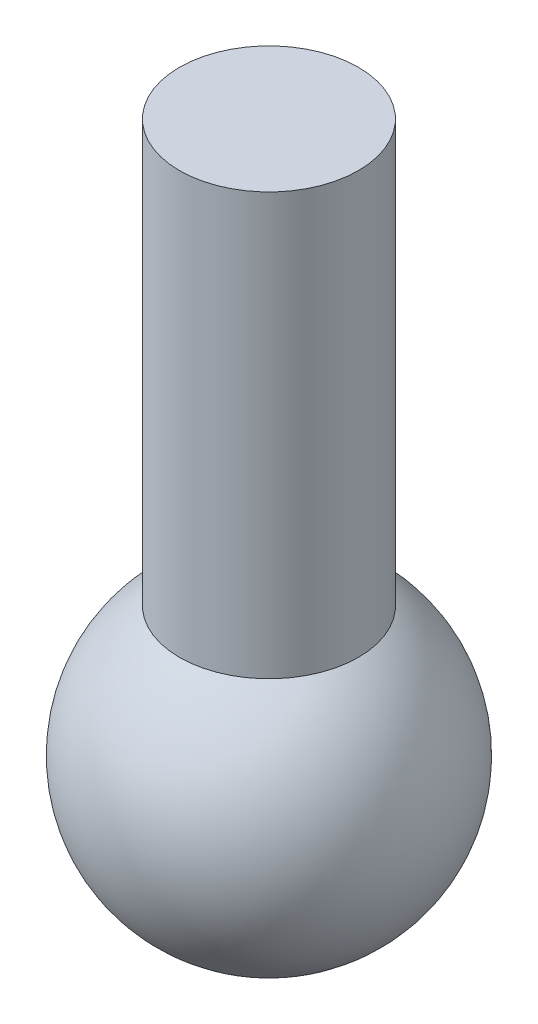
from build123d import *

# Parameters (mm, degrees)
EXTRUDE_2_REACH = 11.9
SKETCH_3_R      = 1.25


with BuildPart() as part:
    # 스케치1 → 회전6 (revolve)
    with BuildSketch(Plane(origin=(0, 0, 0), x_dir=(1, 0, 0), z_dir=(0, 1, 0))):
        with BuildLine():
            Line((0, 2.2), (0, -2.2))
            ThreePointArc((0, -2.2), (2.2, 0), (0, 2.2))
        make_face()
    revolve(axis=Axis((0, 0, -3.610555553), (0, 0, 1)))

    # 스케치3 → 보스-돌출2 (add, up to next)
    with BuildSketch(Plane(origin=(0, 7.7, 0), x_dir=(1, 0, 0), z_dir=(0, 1, 0)), mode=Mode.PRIVATE) as extrude_2_sk1:
        Circle(SKETCH_3_R)
    extrude_2_tool1 = extrude(extrude_2_sk1.sketch, amount=-EXTRUDE_2_REACH, mode=Mode.PRIVATE) - part.part
    add(extrude_2_tool1.solids().sort_by_distance((0, 7.7, 0))[0])


solid = part.part
